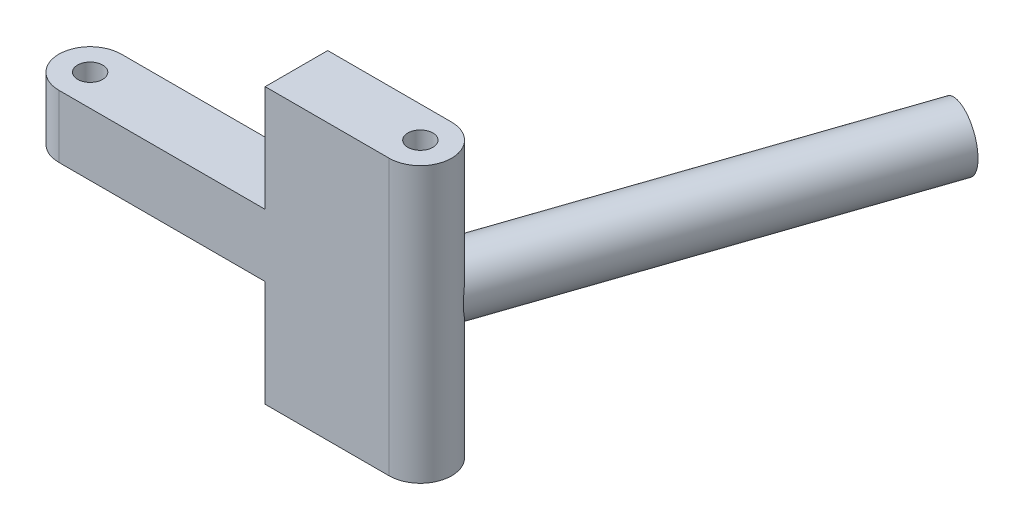
from build123d import *

# Parameters (mm, degrees)
BOSS_EXTRUDE1_DEPTH = 22
SKETCH2_R           = 1
CUT_EXTRUDE1_DEPTH  = 22
SKETCH3_W           = 5
SKETCH3_H           = 8.5
CUT_EXTRUDE7_DEPTH  = 19
BOSS_EXTRUDE3_START = -0.815625
SKETCH5_R           = 2.4
BOSS_EXTRUDE3_DEPTH = 32.815625


with BuildPart() as part:
    # Sketch1 → Boss-Extrude1 (new body)
    with BuildSketch(Plane(origin=(0, 0, 0), x_dir=(1, 0, 0), z_dir=(0, 1, 0))):
        with BuildLine():
            Line((0, 2.5), (26.41, 2.5))
            ThreePointArc((26.41, 2.5), (28.91, 0), (26.41, -2.5))
            Line((26.41, -2.5), (0, -2.5))
            ThreePointArc((0, -2.5), (-2.5, 0), (0, 2.5))
        make_face()
    extrude(amount=BOSS_EXTRUDE1_DEPTH)

    # Sketch2 → Cut-Extrude1 (cut)
    with BuildSketch(Plane(origin=(0, 22, 0), x_dir=(1, 0, 0), z_dir=(0, 1, 0))):
        Circle(SKETCH2_R)
        with Locations((26.41, 0)):
            Circle(SKETCH2_R)
    extrude(amount=-CUT_EXTRUDE1_DEPTH, mode=Mode.SUBTRACT)

    # Sketch3 → Cut-Extrude7 (cut)
    with BuildSketch(Plane(origin=(-2.5, 0, 0), x_dir=(0, 0, -1), z_dir=(1, 0, 0))):
        with Locations((0, 17.75)):
            Rectangle(SKETCH3_W, SKETCH3_H)
        with Locations((0, 4.25)):
            Rectangle(SKETCH3_W, SKETCH3_H)
    extrude(amount=CUT_EXTRUDE7_DEPTH, mode=Mode.SUBTRACT)

    # Sketch5 → Boss-Extrude3 (add)
    with BuildSketch(Plane(origin=(3.496027694, 0, -10.287166689), x_dir=(0, -1, 0), z_dir=(0.321769987, 0, -0.946817868)).offset(BOSS_EXTRUDE3_START)):
        with Locations((-11, -24.201034934)):
            Circle(SKETCH5_R)
    extrude(amount=BOSS_EXTRUDE3_DEPTH)


solid = part.part
